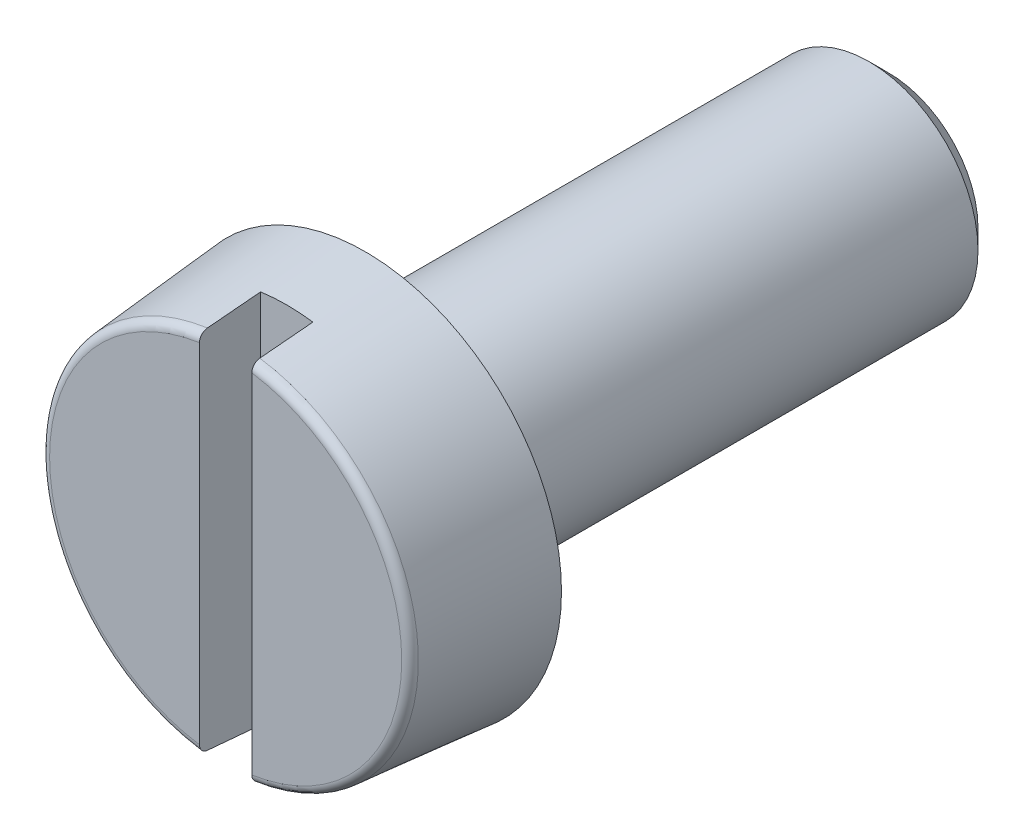
from build123d import *

# Parameters (mm, degrees)
SKETCH2_W          = 0.6
SKETCH2_H          = 4.5
CUT_EXTRUDE1_DEPTH = 0.7


with BuildPart() as part:
    # Sketch1 → Revolve1 (revolve)
    with BuildSketch(Plane(origin=(0, 0, 0), x_dir=(0, 0, -1), z_dir=(1, 0, 0))):
        with BuildLine():
            Line((0, 0), (0, 2.018385021))
            ThreePointArc((0, 2.018385021), (0.026272266, 2.085944042), (0.091284426, 2.118004491))
            Line((0.091284426, 2.118004491), (1.6, 2.25))
            Line((1.6, 2.25), (1.6, 1.35))
            ThreePointArc((1.6, 1.35), (1.629289322, 1.279289322), (1.7, 1.25))
            Line((1.7, 1.25), (7.375, 1.25))
            Line((7.375, 1.25), (7.6, 1.025))
            Line((7.6, 1.025), (7.6, 0))
            Line((7.6, 0), (0, 0))
        make_face()
    revolve(axis=Axis((0, 0, 0), (0, 0, -1)))

    # Sketch2 → Cut-Extrude1 (cut)
    with BuildSketch(Plane.XY):
        Rectangle(SKETCH2_W, SKETCH2_H)
    extrude(amount=-CUT_EXTRUDE1_DEPTH, mode=Mode.SUBTRACT)


solid = part.part
